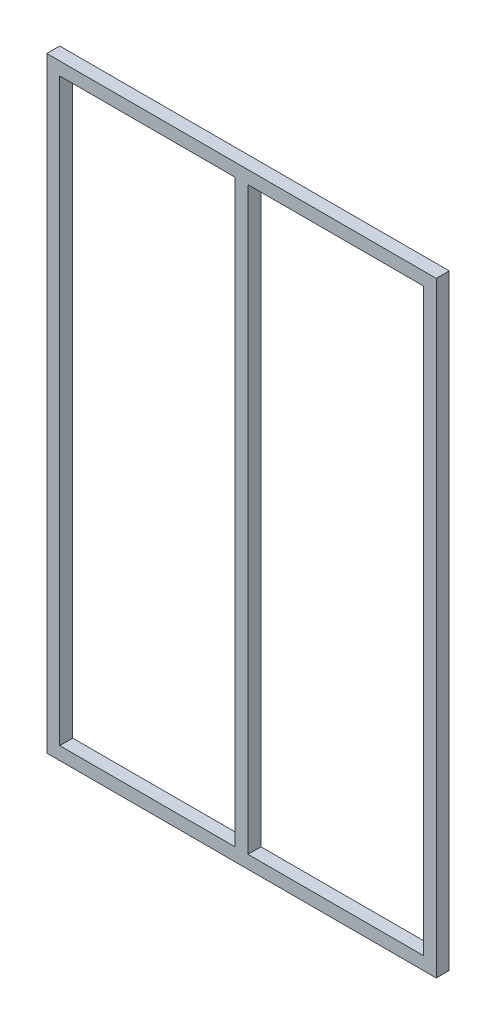
from build123d import *

# Parameters (mm, degrees)
SKETCH1_W           = 571.5
SKETCH1_H           = 889
BOSS_EXTRUDE1_DEPTH = 19.05
SKETCH2_W           = 257.175
SKETCH2_H           = 850.9
CUT_EXTRUDE1_DEPTH  = 20.05


with BuildPart() as part:
    # Sketch1 → Boss-Extrude1 (new body)
    with BuildSketch(Plane.XY):
        Rectangle(SKETCH1_W, SKETCH1_H)
    extrude(amount=-BOSS_EXTRUDE1_DEPTH)

    # Sketch2 → Cut-Extrude1 (cut, through all)
    with BuildSketch(Plane.XY):
        with Locations((-138.1125, 0)):
            Rectangle(SKETCH2_W, SKETCH2_H)
        with Locations((138.1125, 0)):
            Rectangle(SKETCH2_W, SKETCH2_H)
    extrude(amount=-CUT_EXTRUDE1_DEPTH, mode=Mode.SUBTRACT)


solid = part.part
